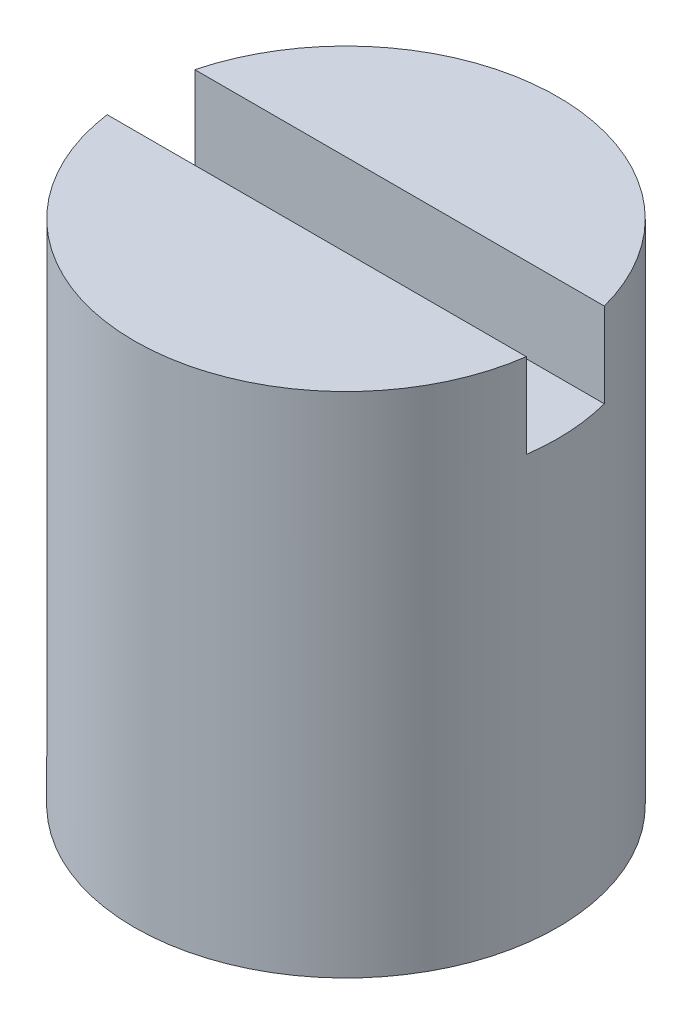
from build123d import *

# Parameters (mm, degrees)
SKETCH1_R           = 7.5
BOSS_EXTRUDE1_DEPTH = 18
SKETCH2_W           = 24.164210644
SKETCH2_H           = 2.935838677
CUT_EXTRUDE1_DEPTH  = 3


with BuildPart() as part:
    # Sketch1 → Boss-Extrude1 (new body)
    with BuildSketch(Plane(origin=(0, 0, 0), x_dir=(1, 0, 0), z_dir=(0, 1, 0))):
        Circle(SKETCH1_R)
    extrude(amount=BOSS_EXTRUDE1_DEPTH)

    # Sketch2 → Cut-Extrude1 (cut)
    with BuildSketch(Plane(origin=(0, 18, 0), x_dir=(1, 0, 0), z_dir=(0, 1, 0))):
        with Locations((-0.598960247, 0.431137149)):
            Rectangle(SKETCH2_W, SKETCH2_H)
    extrude(amount=-CUT_EXTRUDE1_DEPTH, mode=Mode.SUBTRACT)


solid = part.part
